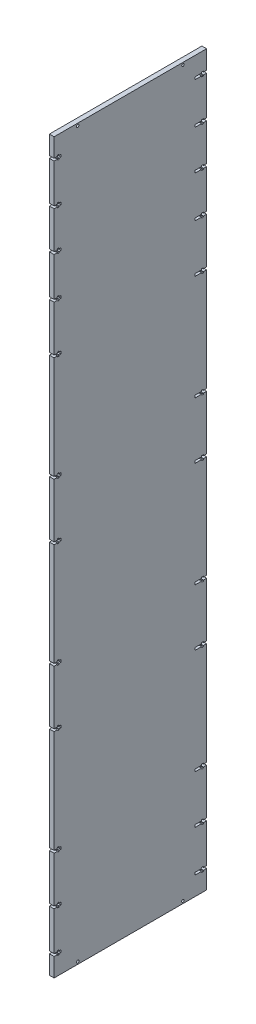
from build123d import *

# Parameters (mm, degrees)
BOSS_EXTRUDE1_DEPTH = 5.8
SKETCH2_R           = 1.55
CUT_EXTRUDE1_DEPTH  = 5.8
SKETCH3_W           = 6
SKETCH3_H           = 3
CUT_EXTRUDE2_DEPTH  = 5.8


with BuildPart() as part:
    # Sketch1 → Boss-Extrude1 (new body)
    with BuildSketch(Plane(origin=(0, 0, 0), x_dir=(0, 0, -1), z_dir=(1, 0, 0))):
        Polygon((0, 23), (0, 0), (188.4, 0), (188.4, 23), (184.4, 23), (184.4, 21.79), (182.05, 21.79), (182.05, 23), (180.05, 23), (180.05, 26), (182.05, 26), (182.05, 27.21), (184.4, 27.21), (184.4, 26), (188.4, 26), (188.4, 74), (184.4, 74), (184.4, 72.79), (182.05, 72.79), (182.05, 74), (180.05, 74), (180.05, 77), (182.05, 77), (182.05, 78.21), (184.4, 78.21), (184.4, 77), (188.4, 77), (188.4, 133.5), (184.4, 133.5), (184.4, 132.29), (182.05, 132.29), (182.05, 133.5), (180.05, 133.5), (180.05, 136.5), (182.05, 136.5), (182.05, 137.71), (184.4, 137.71), (184.4, 136.5), (188.4, 136.5), (188.4, 263.5), (184.4, 263.5), (184.4, 262.29), (182.05, 262.29), (182.05, 263.5), (180.05, 263.5), (180.05, 266.5), (182.05, 266.5), (182.05, 267.71), (184.4, 267.71), (184.4, 266.5), (188.4, 266.5), (188.4, 333.5), (184.4, 333.5), (184.4, 332.29), (182.05, 332.29), (182.05, 333.5), (180.05, 333.5), (180.05, 336.5), (182.05, 336.5), (182.05, 337.71), (184.4, 337.71), (184.4, 336.5), (188.4, 336.5), (188.4, 463.5), (184.4, 463.5), (184.4, 462.29), (182.05, 462.29), (182.05, 463.5), (180.05, 463.5), (180.05, 466.5), (182.05, 466.5), (182.05, 467.71), (184.4, 467.71), (184.4, 466.5), (188.4, 466.5), (188.4, 533.5), (184.4, 533.5), (184.4, 532.29), (182.05, 532.29), (182.05, 533.5), (180.05, 533.5), (180.05, 536.5), (182.05, 536.5), (182.05, 537.71), (184.4, 537.71), (184.4, 536.5), (188.4, 536.5), (188.4, 663.5), (184.4, 663.5), (184.4, 662.29), (182.05, 662.29), (182.05, 663.5), (180.05, 663.5), (180.05, 666.5), (182.05, 666.5), (182.05, 667.71), (184.4, 667.71), (184.4, 666.5), (188.4, 666.5), (188.4, 723), (184.4, 723), (184.4, 721.79), (182.05, 721.79), (182.05, 723), (180.05, 723), (180.05, 726), (182.05, 726), (182.05, 727.21), (184.4, 727.21), (184.4, 726), (188.4, 726), (188.4, 774), (184.4, 774), (184.4, 772.79), (182.05, 772.79), (182.05, 774), (180.05, 774), (180.05, 777), (182.05, 777), (182.05, 778.21), (184.4, 778.21), (184.4, 777), (188.4, 777), (188.4, 823), (184.4, 823), (184.4, 821.79), (182.05, 821.79), (182.05, 823), (180.05, 823), (180.05, 826), (182.05, 826), (182.05, 827.21), (184.4, 827.21), (184.4, 826), (188.4, 826), (188.4, 874), (184.4, 874), (184.4, 872.79), (182.05, 872.79), (182.05, 874), (180.05, 874), (180.05, 877), (182.05, 877), (182.05, 878.21), (184.4, 878.21), (184.4, 877), (188.4, 877), (188.4, 900), (0, 900), (0, 877), (4, 877), (4, 878.21), (6.35, 878.21), (6.35, 877), (8.35, 877), (8.35, 874), (6.35, 874), (6.35, 872.79), (4, 872.79), (4, 874), (0, 874), (0, 826), (4, 826), (4, 827.21), (6.35, 827.21), (6.35, 826), (8.35, 826), (8.35, 823), (6.35, 823), (6.35, 821.79), (4, 821.79), (4, 823), (0, 823), (0, 777), (4, 777), (4, 778.21), (6.35, 778.21), (6.35, 777), (8.35, 777), (8.35, 774), (6.35, 774), (6.35, 772.79), (4, 772.79), (4, 774), (0, 774), (0, 726), (4, 726), (4, 727.21), (6.35, 727.21), (6.35, 726), (8.35, 726), (8.35, 723), (6.35, 723), (6.35, 721.79), (4, 721.79), (4, 723), (0, 723), (0, 666.5), (4, 666.5), (4, 667.71), (6.35, 667.71), (6.35, 666.5), (8.35, 666.5), (8.35, 663.5), (6.35, 663.5), (6.35, 662.29), (4, 662.29), (4, 663.5), (0, 663.5), (0, 536.5), (4, 536.5), (4, 537.71), (6.35, 537.71), (6.35, 536.5), (8.35, 536.5), (8.35, 533.5), (6.35, 533.5), (6.35, 532.29), (4, 532.29), (4, 533.5), (0, 533.5), (0, 466.5), (4, 466.5), (4, 467.71), (6.35, 467.71), (6.35, 466.5), (8.35, 466.5), (8.35, 463.5), (6.35, 463.5), (6.35, 462.29), (4, 462.29), (4, 463.5), (0, 463.5), (0, 336.5), (4, 336.5), (4, 337.71), (6.35, 337.71), (6.35, 336.5), (8.35, 336.5), (8.35, 333.5), (6.35, 333.5), (6.35, 332.29), (4, 332.29), (4, 333.5), (0, 333.5), (0, 266.5), (4, 266.5), (4, 267.71), (6.35, 267.71), (6.35, 266.5), (8.35, 266.5), (8.35, 263.5), (6.35, 263.5), (6.35, 262.29), (4, 262.29), (4, 263.5), (0, 263.5), (0, 136.5), (4, 136.5), (4, 137.71), (6.35, 137.71), (6.35, 136.5), (8.35, 136.5), (8.35, 133.5), (6.35, 133.5), (6.35, 132.29), (4, 132.29), (4, 133.5), (0, 133.5), (0, 77), (4, 77), (4, 78.21), (6.35, 78.21), (6.35, 77), (8.35, 77), (8.35, 74), (6.35, 74), (6.35, 72.79), (4, 72.79), (4, 74), (0, 74), (0, 26), (4, 26), (4, 27.21), (6.35, 27.21), (6.35, 26), (8.35, 26), (8.35, 23), (6.35, 23), (6.35, 21.79), (4, 21.79), (4, 23), align=None)
    extrude(amount=BOSS_EXTRUDE1_DEPTH)

    # Sketch2 → Cut-Extrude1 (cut)
    with BuildSketch(Plane(origin=(5.8, 0, 0), x_dir=(0, 0, -1), z_dir=(1, 0, 0))):
        with Locations((159.2, 897.1)):
            Circle(SKETCH2_R)
        with Locations((29.2, 897.1)):
            Circle(SKETCH2_R)
        with Locations((159.2, 2.9)):
            Circle(SKETCH2_R)
        with Locations((29.2, 2.9)):
            Circle(SKETCH2_R)
    extrude(amount=-CUT_EXTRUDE1_DEPTH, mode=Mode.SUBTRACT)

    # Sketch3 → Cut-Extrude2 (cut)
    with BuildSketch(Plane(origin=(5.8, 0, 0), x_dir=(0, 0, -1), z_dir=(1, 0, 0))):
        with Locations((177.05, 875.5)):
            Rectangle(SKETCH3_W, SKETCH3_H)
        with Locations((177.05, 824.5)):
            Rectangle(SKETCH3_W, SKETCH3_H)
        with Locations((177.05, 775.5)):
            Rectangle(SKETCH3_W, SKETCH3_H)
        with Locations((177.05, 724.5)):
            Rectangle(SKETCH3_W, SKETCH3_H)
        with Locations((177.05, 665)):
            Rectangle(SKETCH3_W, SKETCH3_H)
        with Locations((177.05, 535)):
            Rectangle(SKETCH3_W, SKETCH3_H)
        with Locations((177.05, 465)):
            Rectangle(SKETCH3_W, SKETCH3_H)
        with Locations((177.05, 335)):
            Rectangle(SKETCH3_W, SKETCH3_H)
        with Locations((177.05, 265)):
            Rectangle(SKETCH3_W, SKETCH3_H)
        with Locations((177.05, 135)):
            Rectangle(SKETCH3_W, SKETCH3_H)
        with Locations((177.05, 75.5)):
            Rectangle(SKETCH3_W, SKETCH3_H)
        with Locations((177.05, 24.5)):
            Rectangle(SKETCH3_W, SKETCH3_H)
    extrude(amount=-CUT_EXTRUDE2_DEPTH, mode=Mode.SUBTRACT)


solid = part.part
